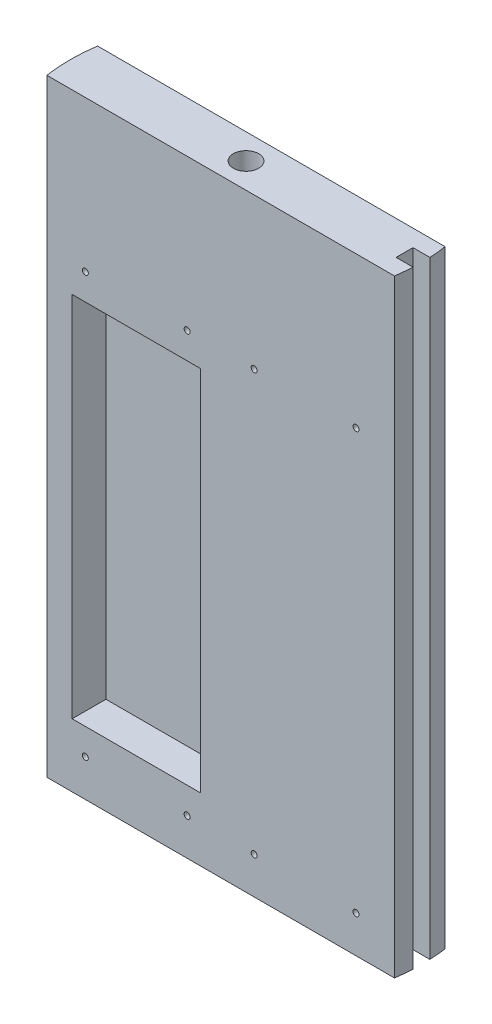
from build123d import *

# Parameters (mm, degrees)
BOSS_EXTRUDE1_DEPTH   = 228.6
SKETCH3_R             = 4.7625
CUT_EXTRUDE1_DEPTH    = 229.6
F_4_40_TAPPED_HOLE1_D = 2.2606
CUT_EXTRUDE2_DEPTH    = 229.6
SKETCH7_W             = 48.175
SKETCH7_H             = 138.175
CUT_EXTRUDE3_DEPTH    = 12.7
SKETCH8_W             = 48.175
SKETCH8_H             = 138.175
CUT_EXTRUDE4_DEPTH    = 12.7


with BuildPart() as part:
    # Sketch1 → Boss-Extrude1 (new body)
    with BuildSketch(Plane(origin=(0, 0, 0), x_dir=(1, 0, 0), z_dir=(0, 1, 0))):
        with BuildLine():
            Line((-65.349491008, -9.525), (65.349491008, -9.525))
            ThreePointArc((65.349491008, -9.525), (66.04, 0), (65.349491008, 9.525))
            Line((65.349491008, 9.525), (-65.349491008, 9.525))
            ThreePointArc((-65.349491008, 9.525), (-66.04, 0), (-65.349491008, -9.525))
        make_face()
    extrude(amount=-BOSS_EXTRUDE1_DEPTH)

    # Sketch3 → Cut-Extrude1 (cut, through all)
    with BuildSketch(Plane(origin=(0, 0, 0), x_dir=(1, 0, 0), z_dir=(0, 1, 0))):
        Circle(SKETCH3_R)
    extrude(amount=-CUT_EXTRUDE1_DEPTH, mode=Mode.SUBTRACT)

    # #4-40 Tapped Hole1 (through all)
    with Locations(Plane.XY.offset(9.525)):
        with Locations((-50.895394878, -56.7192), (-12.604605122, -56.7192), (-12.604605122, -214.6808), (-50.895394878, -214.6808), (12.604605122, -56.7192), (50.895394878, -56.7192), (12.604605122, -214.6808), (50.895394878, -214.6808)):
            Hole(F_4_40_TAPPED_HOLE1_D / 2)

    # Sketch6 → Cut-Extrude2 (cut, through all)
    with BuildSketch(Plane.XZ.offset(228.6)):
        with BuildLine():
            Line((59.613633731, 3.175), (65.963633731, 3.175))
            ThreePointArc((65.963633731, 3.175), (66.04, 0), (65.963633731, -3.175))
            Line((65.963633731, -3.175), (59.613633731, -3.175))
            Line((59.613633731, -3.175), (59.613633731, 3.175))
        make_face()
    extrude(amount=-CUT_EXTRUDE2_DEPTH, mode=Mode.SUBTRACT)

    # Sketch7 → Cut-Extrude3 (cut)
    with BuildSketch(Plane.XY.offset(9.525)):
        with Locations((-31.75, -135.7)):
            Rectangle(SKETCH7_W, SKETCH7_H)
    extrude(amount=-CUT_EXTRUDE3_DEPTH, mode=Mode.SUBTRACT)

    # Sketch8 → Cut-Extrude4 (cut)
    with BuildSketch(Plane(origin=(0, 0, -9.525), x_dir=(-1, 0, 0), z_dir=(0, 0, -1))):
        with Locations((-31.75, -135.7)):
            Rectangle(SKETCH8_W, SKETCH8_H)
    extrude(amount=-CUT_EXTRUDE4_DEPTH, mode=Mode.SUBTRACT)


solid = part.part
